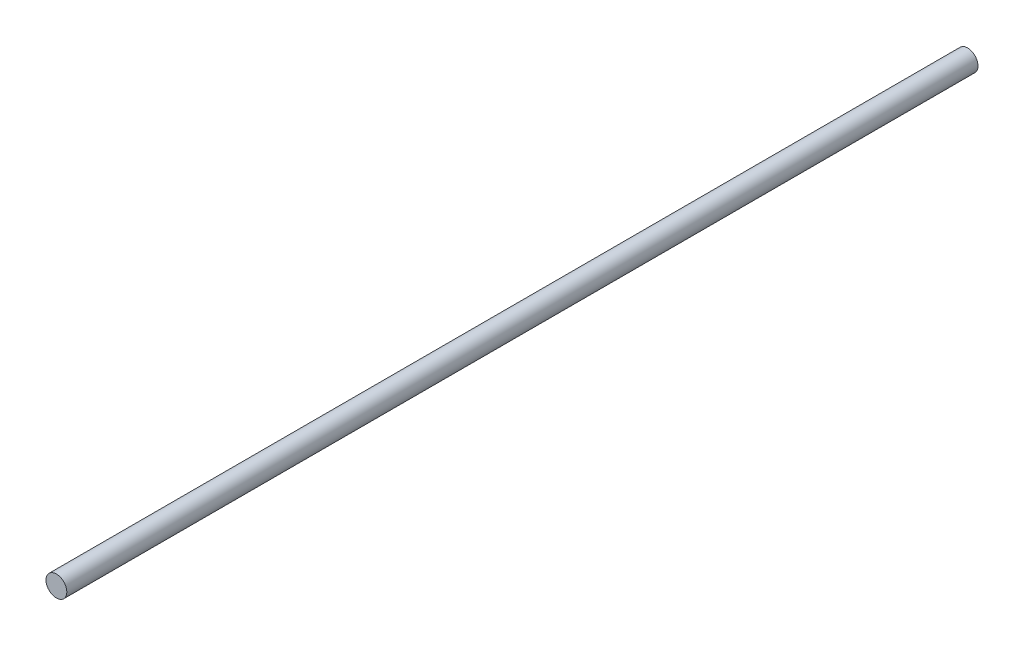
from build123d import *

# Parameters (mm, degrees)
SKETCH1_R           = 4
BOSS_EXTRUDE1_DEPTH = 350


with BuildPart() as part:
    # Sketch1 → Boss-Extrude1 (new body)
    with BuildSketch(Plane.XY):
        Circle(SKETCH1_R)
    extrude(amount=BOSS_EXTRUDE1_DEPTH)


solid = part.part
